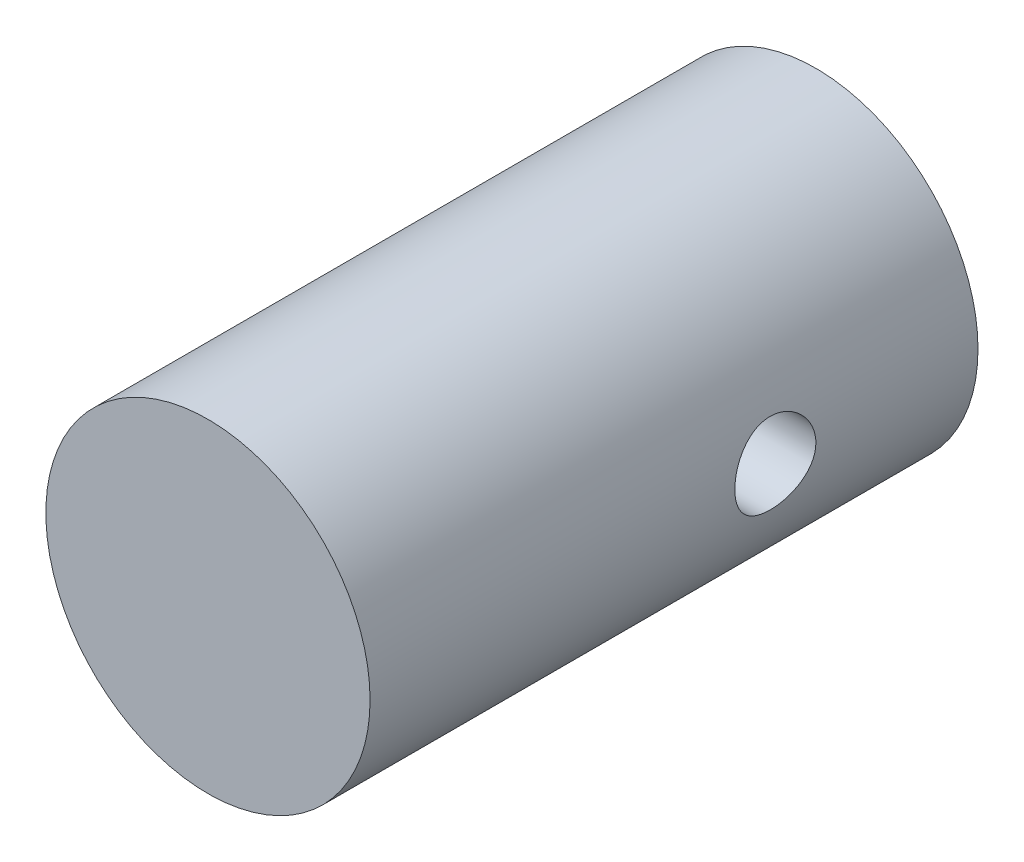
from build123d import *

# Parameters (mm, degrees)
SKETCH_1_R          = 8
EXTRUDE_1_DEPTH     = 30
SKETCH_2_R          = 2
CUT_EXTRUDE_1_DEPTH = 31


with BuildPart() as part:
    # 草图1 → 凸台-拉伸1 (new body)
    with BuildSketch(Plane.XY):
        with Locations((-16.070026793, 15.571731389)):
            Circle(SKETCH_1_R)
    extrude(amount=EXTRUDE_1_DEPTH)

    # 草图2 → 切除-拉伸1 (cut)
    with BuildSketch(Plane(origin=(0, 0, 0), x_dir=(0, 0, -1), z_dir=(1, 0, 0))):
        with Locations((-10, 15.571731389)):
            Circle(SKETCH_2_R)
    extrude(amount=-CUT_EXTRUDE_1_DEPTH, mode=Mode.SUBTRACT)


solid = part.part
